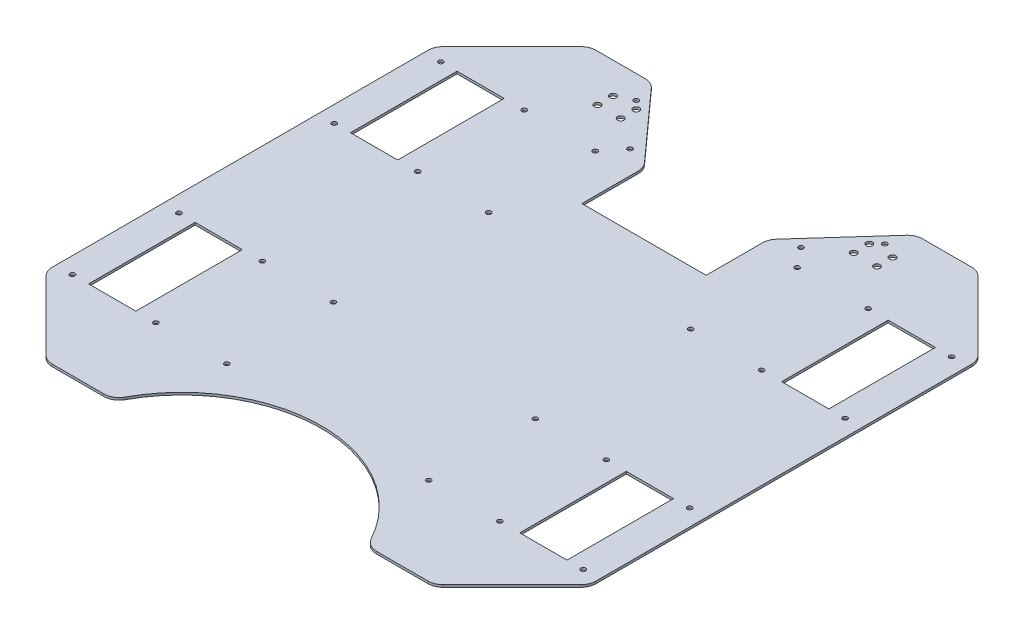
from build123d import *

# Parameters (mm, degrees)
SKETCH_1_R          = 1.55
SKETCH_1_W          = 30.4
SKETCH_1_H          = 68.58
EXTRUDE_1_DEPTH     = 1.5
FILLET_1_R          = 10
FILLET_2_R          = 10
FILLET_3_R          = 10
SKETCH_1_5_R        = 2.05
CUT_EXTRUDE_3_DEPTH = 10


with BuildPart() as part:
    # 草图1 → 凸台-拉伸1 (new body)
    with BuildSketch(Plane(origin=(0, 0, 0), x_dir=(1, 0, 0), z_dir=(0, 1, 0))):
        with BuildLine():
            Line((-125, 175), (-175, 125))
            Line((-175, 125), (-175, -125))
            Line((-175, -125), (-125, -175))
            Line((-125, -175), (-81.710313025, -175))
            ThreePointArc((-81.710313025, -175), (0, -122.728301649), (81.710313025, -175))
            Line((81.710313025, -175), (125, -175))
            Line((125, -175), (175, -125))
            Line((175, -125), (175, 125))
            Line((175, 125), (125, 175))
            Line((125, 175), (85, 175))
            Line((85, 175), (40, 125))
            Line((40, 125), (40, 85))
            Line((40, 85), (-40, 85))
            Line((-40, 85), (-40, 125))
            Line((-40, 125), (-85, 175))
            Line((-85, 175), (-125, 175))
        make_face()
        with Locations((-55, 131)):
            Circle(SKETCH_1_R, mode=Mode.SUBTRACT)
        with Locations((-80, 160)):
            Circle(SKETCH_1_R, mode=Mode.SUBTRACT)
        with Locations((55, 131)):
            Circle(SKETCH_1_R, mode=Mode.SUBTRACT)
        with Locations((80, 160)):
            Circle(SKETCH_1_R, mode=Mode.SUBTRACT)
        with Locations((-65, 118.58)):
            Circle(SKETCH_1_R, mode=Mode.SUBTRACT)
        with Locations((-65, 50)):
            Circle(SKETCH_1_R, mode=Mode.SUBTRACT)
        with Locations((-110.72, 50)):
            Circle(SKETCH_1_R, mode=Mode.SUBTRACT)
        with Locations((-110.72, 118.58)):
            Circle(SKETCH_1_R, mode=Mode.SUBTRACT)
        with Locations((-164.434, 118.58)):
            Circle(SKETCH_1_R, mode=Mode.SUBTRACT)
        with Locations((-164.434, 50)):
            Circle(SKETCH_1_R, mode=Mode.SUBTRACT)
        with Locations((-65, -118.58)):
            Circle(SKETCH_1_R, mode=Mode.SUBTRACT)
        with Locations((-65, -50)):
            Circle(SKETCH_1_R, mode=Mode.SUBTRACT)
        with Locations((-110.72, -50)):
            Circle(SKETCH_1_R, mode=Mode.SUBTRACT)
        with Locations((-110.72, -118.58)):
            Circle(SKETCH_1_R, mode=Mode.SUBTRACT)
        with Locations((-164.434, -50)):
            Circle(SKETCH_1_R, mode=Mode.SUBTRACT)
        with Locations((-164.434, -118.58)):
            Circle(SKETCH_1_R, mode=Mode.SUBTRACT)
        with Locations((65, 50)):
            Circle(SKETCH_1_R, mode=Mode.SUBTRACT)
        with Locations((110.72, 50)):
            Circle(SKETCH_1_R, mode=Mode.SUBTRACT)
        with Locations((110.72, 118.58)):
            Circle(SKETCH_1_R, mode=Mode.SUBTRACT)
        with Locations((65, 118.58)):
            Circle(SKETCH_1_R, mode=Mode.SUBTRACT)
        with Locations((164.434, 118.58)):
            Circle(SKETCH_1_R, mode=Mode.SUBTRACT)
        with Locations((164.434, 50)):
            Circle(SKETCH_1_R, mode=Mode.SUBTRACT)
        with Locations((164.434, -118.58)):
            Circle(SKETCH_1_R, mode=Mode.SUBTRACT)
        with Locations((164.434, -50)):
            Circle(SKETCH_1_R, mode=Mode.SUBTRACT)
        with Locations((110.72, -50)):
            Circle(SKETCH_1_R, mode=Mode.SUBTRACT)
        with Locations((110.72, -118.58)):
            Circle(SKETCH_1_R, mode=Mode.SUBTRACT)
        with Locations((65, -118.58)):
            Circle(SKETCH_1_R, mode=Mode.SUBTRACT)
        with Locations((65, -50)):
            Circle(SKETCH_1_R, mode=Mode.SUBTRACT)
        with Locations((-138.794, 84.29)):
            Rectangle(SKETCH_1_W, SKETCH_1_H, mode=Mode.SUBTRACT)
        with Locations((138.794, 84.29)):
            Rectangle(SKETCH_1_W, SKETCH_1_H, mode=Mode.SUBTRACT)
        with Locations((-138.794, -84.29)):
            Rectangle(SKETCH_1_W, SKETCH_1_H, mode=Mode.SUBTRACT)
        with Locations((138.794, -84.29)):
            Rectangle(SKETCH_1_W, SKETCH_1_H, mode=Mode.SUBTRACT)
    extrude(amount=EXTRUDE_1_DEPTH)

    # 圆角1
    fillet_1_edges = [part.edges().sort_by_distance(p)[0] for p in [
        (-40, 0.75, -125),
    ]]
    fillet(fillet_1_edges, radius=FILLET_1_R)

    # 圆角2
    fillet_2_edges = [part.edges().sort_by_distance(p)[0] for p in [
        (40, 0.75, -125),
    ]]
    fillet(fillet_2_edges, radius=FILLET_2_R)

    # 圆角3
    fillet_3_edges = [part.edges().sort_by_distance(p)[0] for p in [
        (-85, 0.75, -175),
        (85, 0.75, -175),
        (125, 0.75, -175),
        (175, 0.75, -125),
        (175, 0.75, 125),
        (125, 0.75, 175),
        (81.710313025, 0.75, 175),
        (-81.710313025, 0.75, 175),
        (-125, 0.75, 175),
        (-175, 0.75, 125),
        (-175, 0.75, -125),
        (-125, 0.75, -175),
    ]]
    fillet(fillet_3_edges, radius=FILLET_3_R)

    # 草图1<5> → 切除-拉伸3 (cut)
    with BuildSketch(Plane(origin=(0, 0, 0), x_dir=(1, 0, 0), z_dir=(0, 1, 0))):
        with Locations((-90, 155)):
            Circle(SKETCH_1_5_R)
        with Locations((-75, 155)):
            Circle(SKETCH_1_5_R)
        with Locations((-90, 145)):
            Circle(SKETCH_1_5_R)
        with Locations((-75, 145)):
            Circle(SKETCH_1_5_R)
        with Locations((75, 145)):
            Circle(SKETCH_1_5_R)
        with Locations((90, 145)):
            Circle(SKETCH_1_5_R)
        with Locations((75, 155)):
            Circle(SKETCH_1_5_R)
        with Locations((90, 155)):
            Circle(SKETCH_1_5_R)
    extrude(amount=CUT_EXTRUDE_3_DEPTH, mode=Mode.SUBTRACT)


solid = part.part
